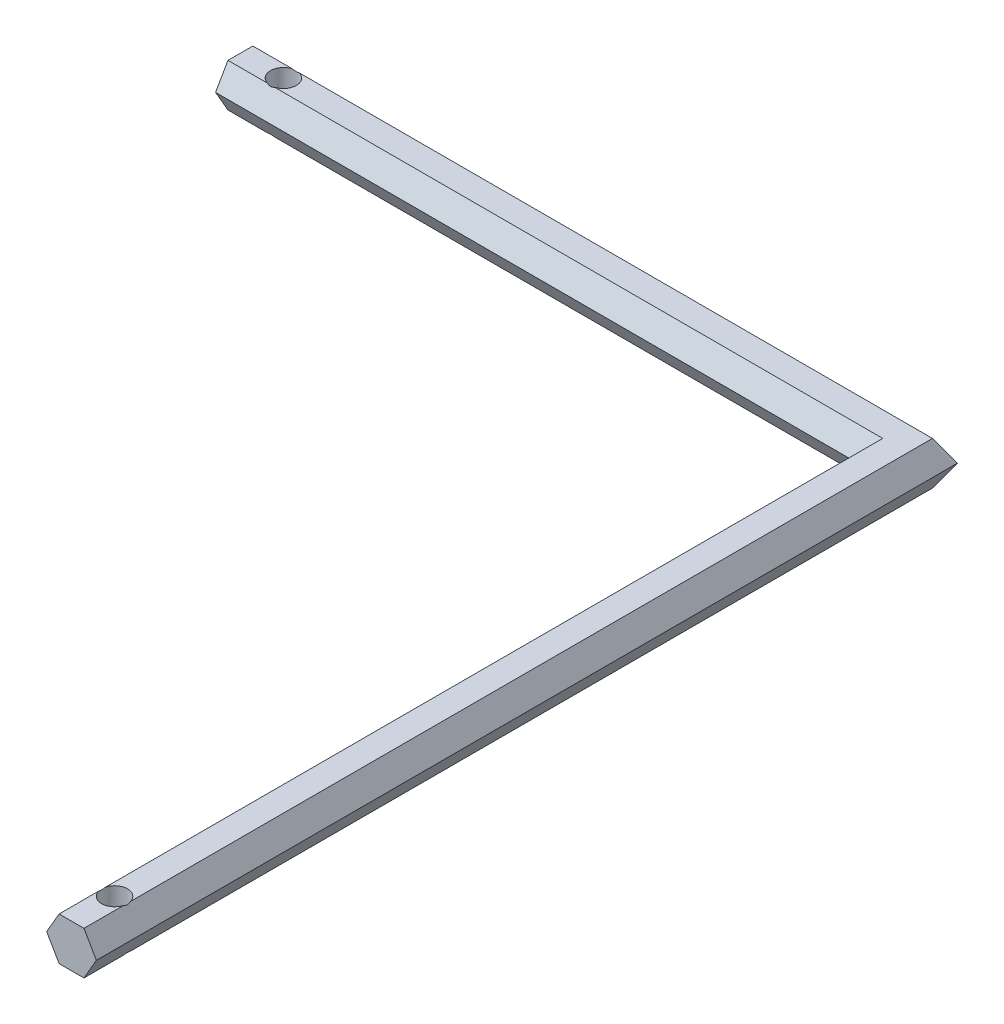
from build123d import *

# Parameters (mm, degrees)
BOSS_EXTRUDE1_DEPTH     = 100
CUT_EXTRUDE1_DEPTH      = 6
CUT_EXTRUDE1_DEPTH_BACK = 6
SKETCH5_R               = 3
CUT_EXTRUDE2_DEPTH      = 6.0000001
CUT_EXTRUDE2_DEPTH_BACK = 6.0000001


with BuildPart() as part:
    # Sketch1 → Boss-Extrude1 (new body, symmetric)
    with BuildSketch(Plane.XY):
        Polygon((-5.773502692, 0), (-2.886751346, -5), (2.886751346, -5), (5.773502692, 0), (2.886751346, 5), (-2.886751346, 5), align=None)
    extrude(amount=BOSS_EXTRUDE1_DEPTH, both=True)

    # Sketch2 → Cut-Extrude1 (cut, two sides)
    with BuildSketch(Plane(origin=(0, 0, 0), x_dir=(1, 0, 0), z_dir=(0, 1, 0))) as cut_extrude1_sk:
        Polygon((5.773502692, 100), (-5.773502692, 88.452994616), (-5.773502692, 100), align=None)
    extrude(amount=CUT_EXTRUDE1_DEPTH, mode=Mode.SUBTRACT)
    extrude(cut_extrude1_sk.sketch, amount=-CUT_EXTRUDE1_DEPTH_BACK, mode=Mode.SUBTRACT)

    # Sketch4 → section 0 of loft1
    with BuildSketch(Plane.ZY.offset(155), mode=Mode.PRIVATE) as loft1_s0:
        Polygon((-97.113248654, 5), (-100, 0), (-97.113248654, -5), (-91.339745962, -5), (-88.452994616, 0), (-91.339745962, 5), align=None)
    # loft up to a face of the part (loft1)
    loft([loft1_s0.sketch, part.faces().sort_by_distance((0, 0, -94.226497308))[0]])

    # Sketch5 → Cut-Extrude2 (cut, two sides)
    with BuildSketch(Plane(origin=(0, 0, 0), x_dir=(1, 0, 0), z_dir=(0, 1, 0))) as cut_extrude2_sk:
        with Locations((0, -90)):
            Circle(SKETCH5_R)
        with Locations((-145, 94.226497308)):
            Circle(SKETCH5_R)
    extrude(amount=CUT_EXTRUDE2_DEPTH, mode=Mode.SUBTRACT)
    extrude(cut_extrude2_sk.sketch, amount=-CUT_EXTRUDE2_DEPTH_BACK, mode=Mode.SUBTRACT)


solid = part.part
